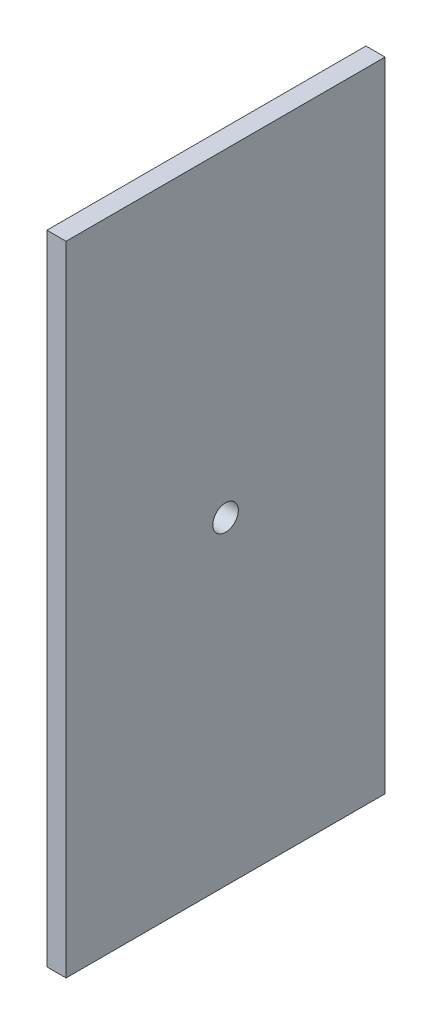
from build123d import *

# Parameters (mm, degrees)
ESQUISSE2_W             = 6
ESQUISSE2_H             = 200
BOSS_EXTRU_1_DEPTH      = 100
ESQUISSE3_R             = 4
ENL_V_MAT_EXTRU_1_DEPTH = 7


with BuildPart() as part:
    # Esquisse2 → Boss.-Extru.1 (new body)
    with BuildSketch(Plane.XY):
        with Locations((3, 60)):
            Rectangle(ESQUISSE2_W, ESQUISSE2_H)
    extrude(amount=BOSS_EXTRU_1_DEPTH)

    # Esquisse3 → Enlèv. mat.-Extru.1 (cut, through all)
    with BuildSketch(Plane(origin=(0, 0, 0), x_dir=(0, 0, -1), z_dir=(1, 0, 0))):
        with Locations((-50, 60)):
            Circle(ESQUISSE3_R)
    extrude(amount=ENL_V_MAT_EXTRU_1_DEPTH, mode=Mode.SUBTRACT)


solid = part.part
